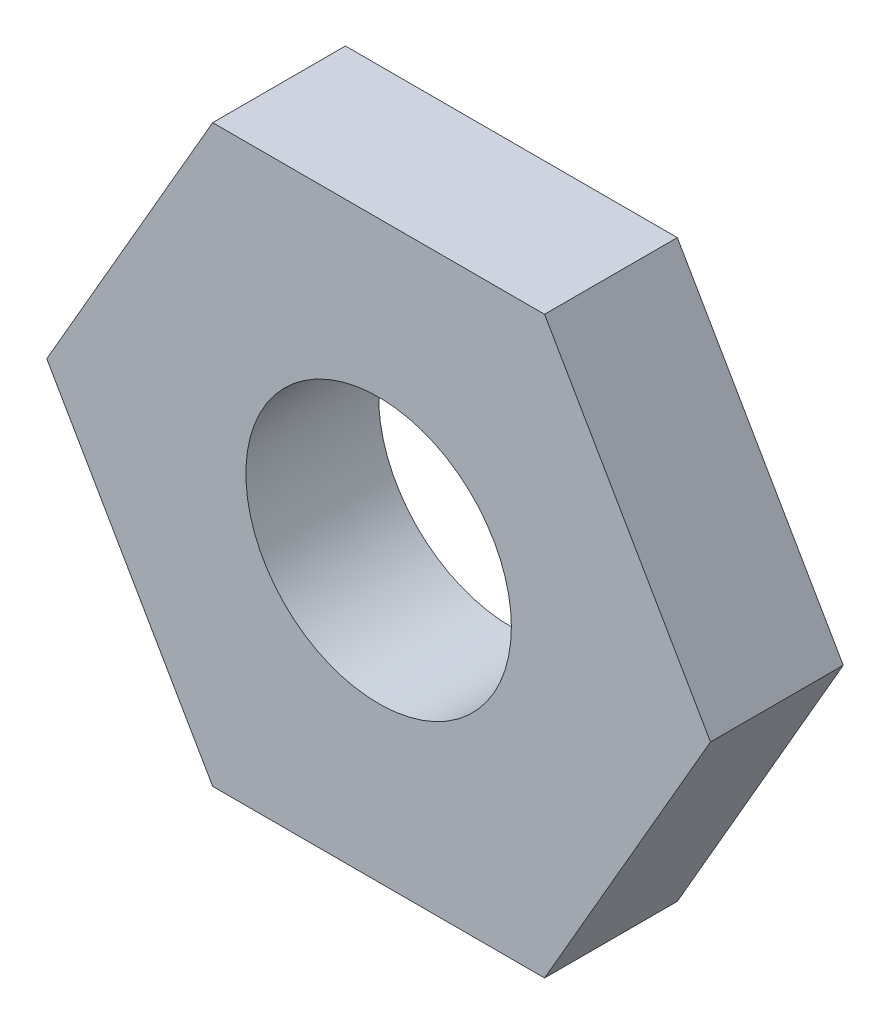
from build123d import *

# Parameters (mm, degrees)
ESQUISSE1_R        = 2
BOSS_EXTRU_1_DEPTH = 2


with BuildPart() as part:
    # Esquisse1 → Boss.-Extru.1 (new body)
    with BuildSketch(Plane.XY):
        Polygon((-5, 0), (-2.5, 4.330127019), (2.5, 4.330127019), (5, 0), (2.499999904, -4.330127185), (-2.500000288, -4.330127185), align=None)
        Circle(ESQUISSE1_R, mode=Mode.SUBTRACT)
    extrude(amount=BOSS_EXTRU_1_DEPTH)


solid = part.part
